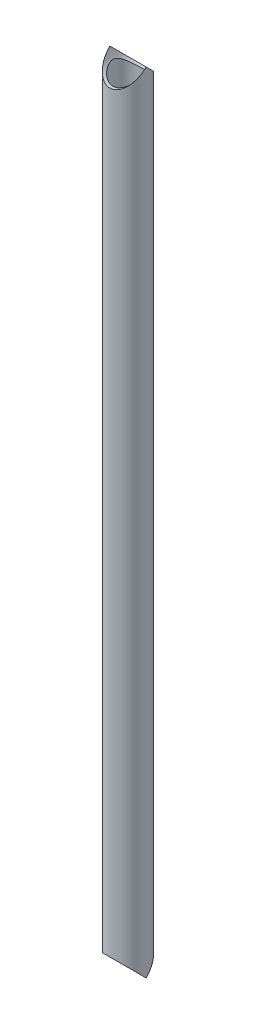
from build123d import *

# Parameters (mm, degrees)
SKETCH1_R               = 21.082
SKETCH1_R_2             = 17.526
BOSS_EXTRUDE1_DEPTH     = 914.4
SKETCH2_R               = 21.082
CUT_EXTRUDE1_DEPTH      = 22.082
CUT_EXTRUDE1_DEPTH_BACK = 22.082


with BuildPart() as part:
    # Sketch1 → Boss-Extrude1 (new body)
    with BuildSketch(Plane(origin=(0, 0, 0), x_dir=(1, 0, 0), z_dir=(0, 1, 0))):
        Circle(SKETCH1_R)
        Circle(SKETCH1_R_2, mode=Mode.SUBTRACT)
    extrude(amount=BOSS_EXTRUDE1_DEPTH)

    # Sketch2 → Cut-Extrude1 (cut, two sides)
    with BuildSketch(Plane.XY) as cut_extrude1_sk:
        Circle(SKETCH2_R)
        with Locations((0, 914.4)):
            Circle(SKETCH2_R)
    extrude(amount=CUT_EXTRUDE1_DEPTH, mode=Mode.SUBTRACT)
    extrude(cut_extrude1_sk.sketch, amount=-CUT_EXTRUDE1_DEPTH_BACK, mode=Mode.SUBTRACT)


solid = part.part
